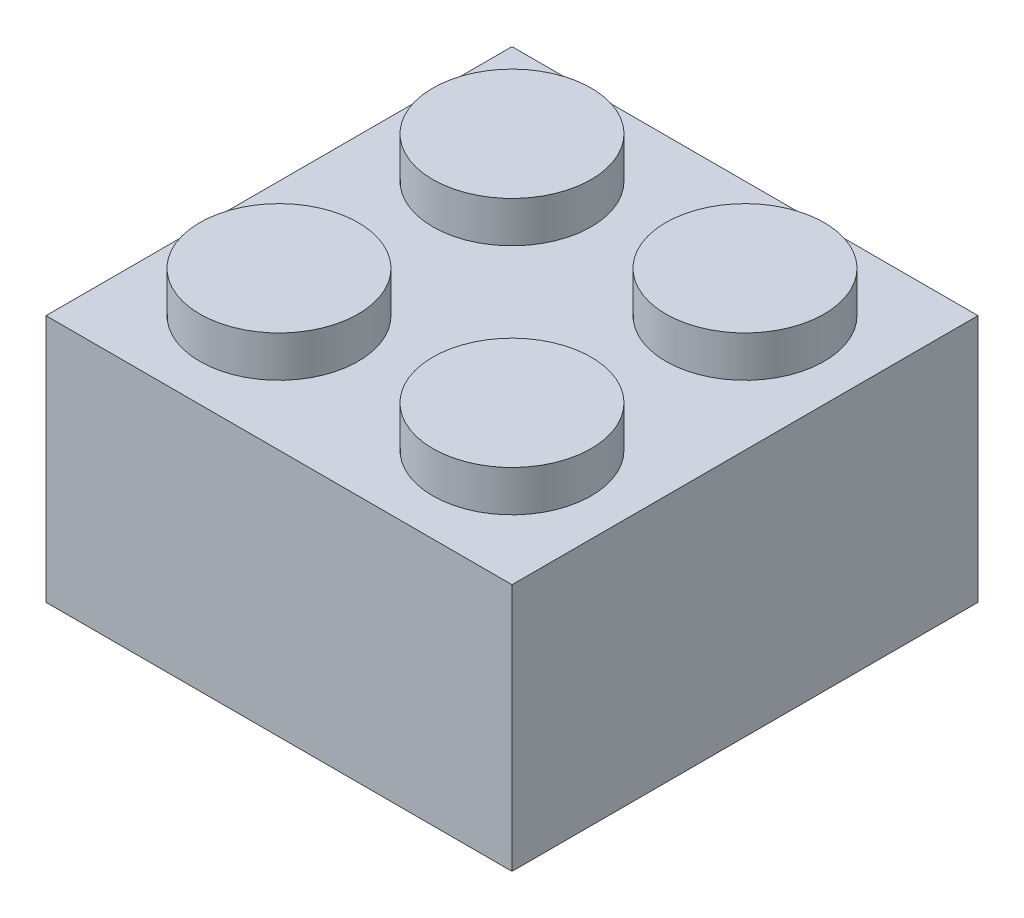
from build123d import *

# Parameters (mm, degrees)
SKETCH1_W           = 15.875
SKETCH1_H           = 15.875
BOSS_EXTRUDE1_DEPTH = 4.2291
SKETCH2_W           = 13.335
SKETCH2_H           = 13.335
SKETCH2_R           = 3.175
SKETCH2_R_2         = 2.413
CUT_EXTRUDE1_DEPTH  = 7.1882
SKETCH3_R           = 2.69875
BOSS_EXTRUDE2_DEPTH = 1.397


with BuildPart() as part:
    # Sketch1 → Boss-Extrude1 (new body, symmetric)
    with BuildSketch(Plane(origin=(0, 0, 0), x_dir=(1, 0, 0), z_dir=(0, 1, 0))):
        Rectangle(SKETCH1_W, SKETCH1_H)
    extrude(amount=BOSS_EXTRUDE1_DEPTH, both=True)

    # Sketch2 → Cut-Extrude1 (cut)
    with BuildSketch(Plane.XZ.offset(4.2291)):
        Rectangle(SKETCH2_W, SKETCH2_H)
        Circle(SKETCH2_R, mode=Mode.SUBTRACT)
        Circle(SKETCH2_R_2)
    extrude(amount=-CUT_EXTRUDE1_DEPTH, mode=Mode.SUBTRACT)

    # Sketch3 → Boss-Extrude2 (add)
    with BuildSketch(Plane(origin=(0, 4.2291, 0), x_dir=(1, 0, 0), z_dir=(0, 1, 0))):
        with Locations((3.96875, -3.96875)):
            Circle(SKETCH3_R)
        with Locations((3.96875, 3.96875)):
            Circle(SKETCH3_R)
        with Locations((-3.96875, -3.96875)):
            Circle(SKETCH3_R)
        with Locations((-3.96875, 3.96875)):
            Circle(SKETCH3_R)
    extrude(amount=BOSS_EXTRUDE2_DEPTH)


solid = part.part
